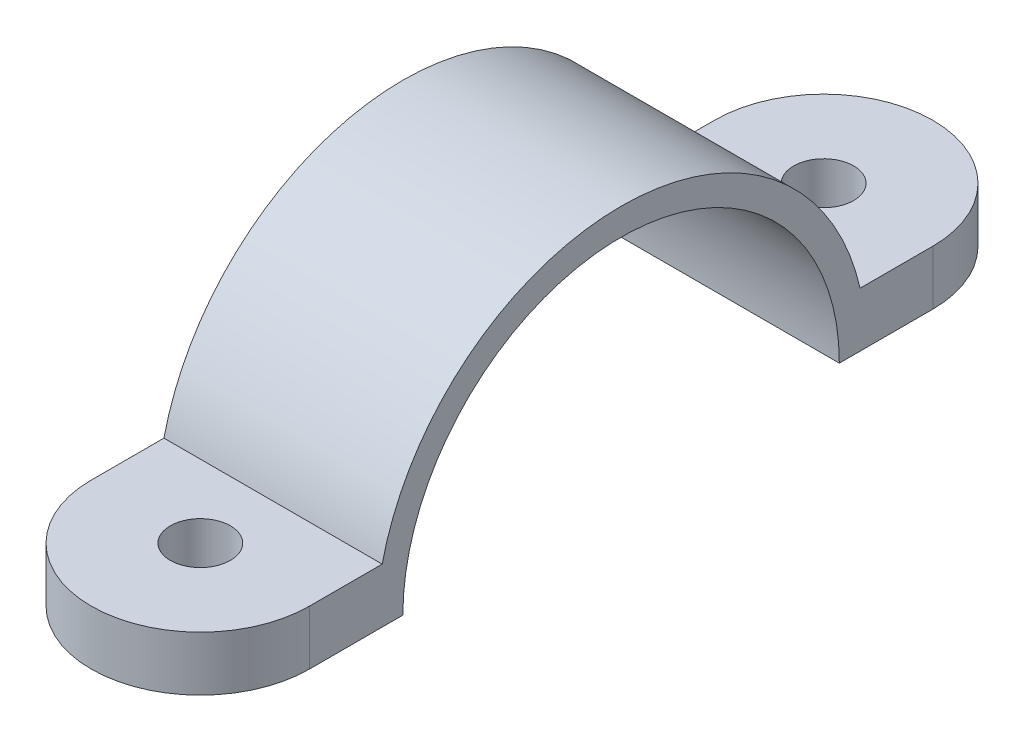
from build123d import *

# Parameters (mm, degrees)
BOSS_EXTRUDE1_DEPTH = 12
SKETCH2_R           = 1.65
CUT_EXTRUDE2_DEPTH  = 14.476258968


with BuildPart() as part:
    # Sketch1 → Boss-Extrude1 (new body)
    with BuildSketch(Plane(origin=(0, 0, 0), x_dir=(0, 0, -1), z_dir=(1, 0, 0))):
        with BuildLine():
            Line((-1.623568234, 0), (9.512622948, 0))
            ThreePointArc((9.512622948, 0), (21.512622948, 12), (33.512622948, 0))
            Line((33.512622948, 0), (44.652622948, 0))
            Line((44.652622948, 0), (44.652622948, 3))
            Line((44.652622948, 3), (34.652622948, 3))
            ThreePointArc((34.652622948, 3), (21.514527357, 13.476258968), (8.376431766, 3))
            Line((8.376431766, 3), (-1.623568234, 3))
            Line((-1.623568234, 3), (-1.623568234, 0))
        make_face()
    extrude(amount=BOSS_EXTRUDE1_DEPTH)

    # Sketch2 → Cut-Extrude2 (cut, through all)
    with BuildSketch(Plane(origin=(0, 0, 0), x_dir=(1, 0, 0), z_dir=(0, 1, 0))):
        with BuildLine():
            Line((0, 44.652622948), (0, 38.652622948))
            ThreePointArc((0, 38.652622948), (1.757359313, 42.895263636), (6, 44.652622948))
            Line((6, 44.652622948), (0, 44.652622948))
        make_face()
        with BuildLine():
            Line((12, 44.652622948), (6, 44.652622948))
            ThreePointArc((6, 44.652622948), (10.242640687, 42.895263636), (12, 38.652622948))
            Line((12, 38.652622948), (12, 44.652622948))
        make_face()
        with BuildLine():
            Line((12, -1.623568234), (12, 4.376431766))
            ThreePointArc((12, 4.376431766), (10.242640687, 0.133791079), (6, -1.623568234))
            Line((6, -1.623568234), (12, -1.623568234))
        make_face()
        with BuildLine():
            Line((0, -1.623568234), (6, -1.623568234))
            ThreePointArc((6, -1.623568234), (1.757359313, 0.133791079), (0, 4.376431766))
            Line((0, 4.376431766), (0, -1.623568234))
        make_face()
        with Locations((6, 4.376431766)):
            Circle(SKETCH2_R)
        with Locations((6, 38.652622948)):
            Circle(SKETCH2_R)
    extrude(amount=CUT_EXTRUDE2_DEPTH, mode=Mode.SUBTRACT)


solid = part.part
